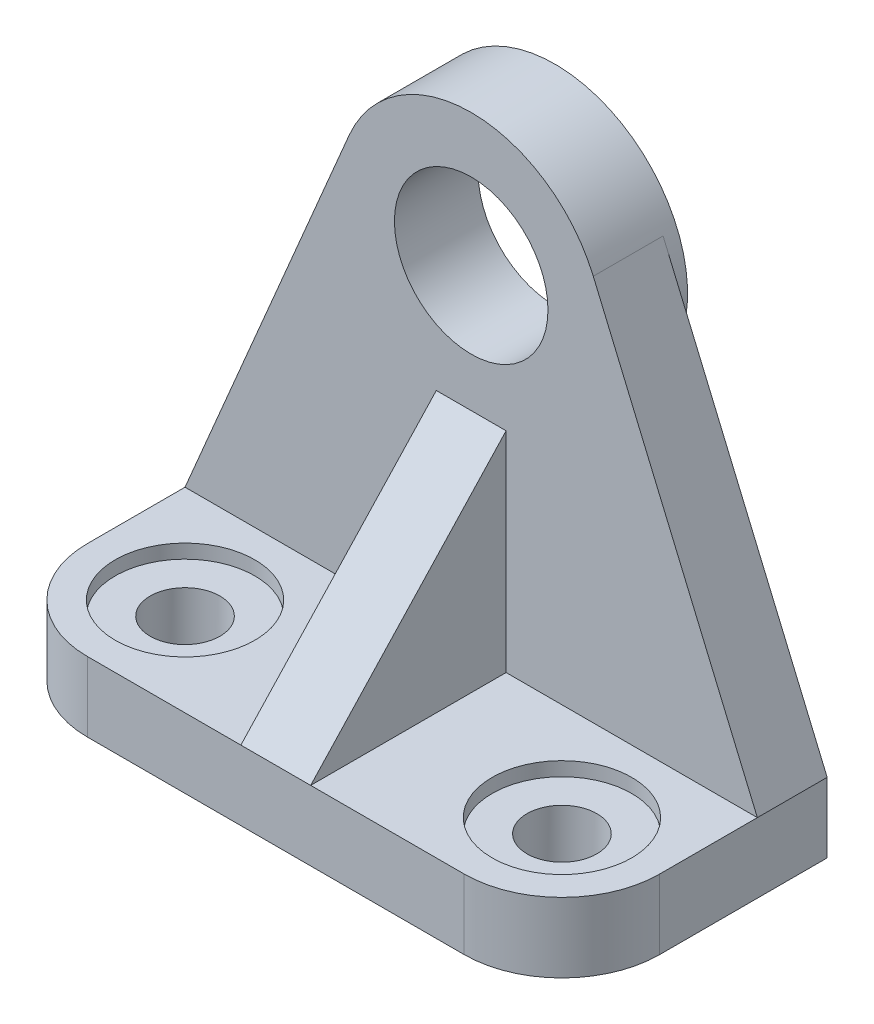
from build123d import *

# Parameters (mm, degrees)
SKETCH1_W           = 41
SKETCH1_H           = 38
BOSS_EXTRUDE1_DEPTH = 10
SKETCH2_R           = 10
SKETCH2_R_2         = 5
CUT_EXTRUDE1_DEPTH  = 2
CUT_EXTRUDE2_REACH  = 58.789
SKETCH2_2_R         = 5
FILLET1_R           = 14
BOSS_EXTRUDE2_DEPTH = 10
BOSS_EXTRUDE3_START = 2
BOSS_EXTRUDE3_DEPTH = 2
BOSS_EXTRUDE4_DEPTH = 5


with BuildPart() as part:
    # Sketch1 → Boss-Extrude1 (new body)
    with BuildSketch(Plane(origin=(0, 0, 0), x_dir=(1, 0, 0), z_dir=(0, 1, 0))):
        with Locations((-20.5, -19)):
            Rectangle(SKETCH1_W, SKETCH1_H)
    extrude(amount=BOSS_EXTRUDE1_DEPTH)

    # Sketch2 → Cut-Extrude1 (cut)
    with BuildSketch(Plane(origin=(0, 10, 0), x_dir=(1, 0, 0), z_dir=(0, 1, 0))):
        with Locations((-27, -24)):
            Circle(SKETCH2_R)
        with Locations((-27, -24)):
            Circle(SKETCH2_R_2, mode=Mode.SUBTRACT)
    extrude(amount=-CUT_EXTRUDE1_DEPTH, mode=Mode.SUBTRACT)

    # Sketch2_2 → Cut-Extrude2 (cut, up to next)
    with BuildSketch(Plane(origin=(0, 10, 0), x_dir=(1, 0, 0), z_dir=(0, 1, 0)), mode=Mode.PRIVATE) as cut_extrude2_sk1:
        with Locations((-27, -24)):
            Circle(SKETCH2_2_R)
    cut_extrude2_tool1 = extrude(cut_extrude2_sk1.sketch, amount=-CUT_EXTRUDE2_REACH, mode=Mode.PRIVATE) & part.part
    add(cut_extrude2_tool1.solids().sort_by_distance((-27, 10, 24))[0], mode=Mode.SUBTRACT)

    # Fillet1
    fillet1_edges = [part.edges().sort_by_distance(p)[0] for p in [
        (-41, 5, 38),
    ]]
    fillet(fillet1_edges, radius=FILLET1_R)

    # Sketch4 → Boss-Extrude2 (add)
    with BuildSketch(Plane.XY):
        with BuildLine():
            ThreePointArc((0, 77), (-10.488696893, 73.842576731), (-17.491366878, 65.419709208))
            Line((-17.491366878, 65.419709208), (-41, 10))
            Line((-41, 10), (0, 10))
            Line((0, 10), (0, 47))
            ThreePointArc((0, 47), (-11, 58), (0, 69))
            Line((0, 69), (0, 77))
        make_face()
    extrude(amount=BOSS_EXTRUDE2_DEPTH)

    # Sketch5 → Boss-Extrude3 (add)
    with BuildSketch(Plane(origin=(0, 0, 0), x_dir=(-1, 0, 0), z_dir=(0, 0, -1)).offset(BOSS_EXTRUDE3_START)):
        with BuildLine():
            Line((0, 47), (0, 39))
            ThreePointArc((0, 39), (13.435028843, 44.564971157), (19, 58))
            ThreePointArc((19, 58), (18.619022137, 61.785764739), (17.491366878, 65.419709208))
            ThreePointArc((17.491366878, 65.419709208), (10.488696893, 73.842576731), (0, 77))
            Line((0, 77), (0, 69))
            ThreePointArc((0, 69), (11, 58), (0, 47))
        make_face()
    extrude(amount=-BOSS_EXTRUDE3_DEPTH)

    # Sketch6 → Boss-Extrude4 (add)
    with BuildSketch(Plane(origin=(0, 0, 0), x_dir=(0, 0, -1), z_dir=(1, 0, 0))):
        Polygon((-38, 10), (-10, 40), (-10, 10), align=None)
    extrude(amount=-BOSS_EXTRUDE4_DEPTH)

    # Mirror1: part across plane


with BuildPart() as part_1:
    add(part.part)
    add(part.part.mirror(Plane(origin=(0, 10, 0), x_dir=(0, 0, 1), z_dir=(-1, 0, 0))))


solid = part_1.part
